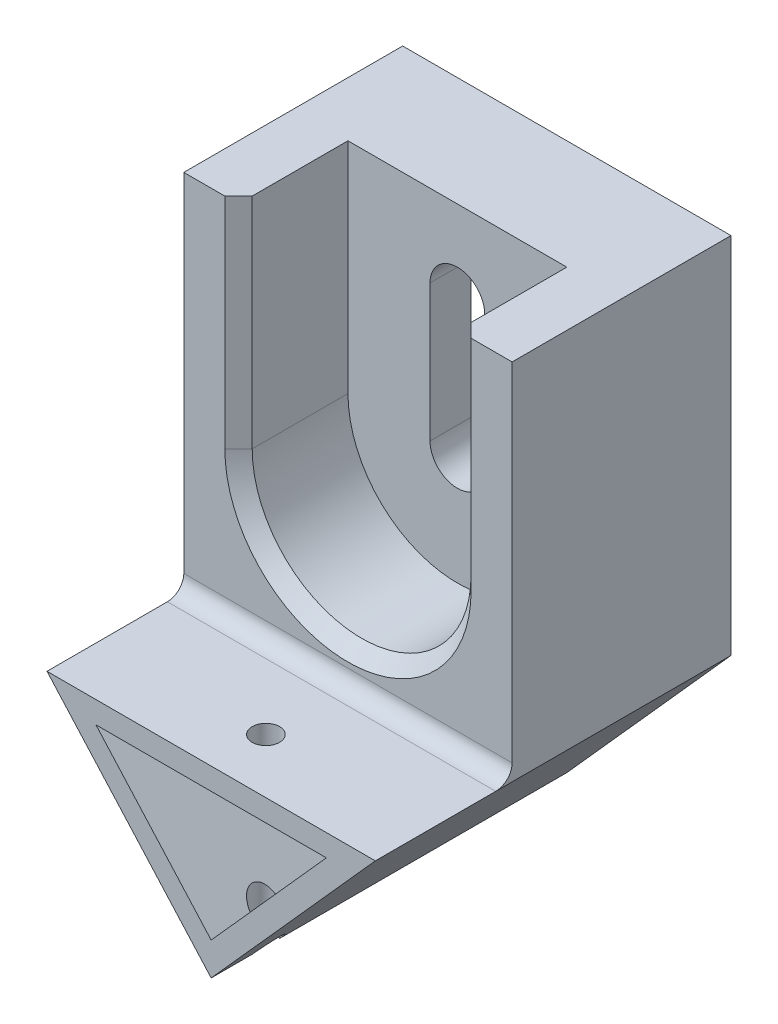
from build123d import *

# Parameters (mm, degrees)
BOSS_EXTRUDE1_DEPTH = 130
SKETCH2_W           = 120
SKETCH2_H           = 132.917960675
BOSS_EXTRUDE2_DEPTH = 80
SKETCH3_R           = 5
CUT_EXTRUDE1_DEPTH  = 68.082039325
CUT_EXTRUDE3_DEPTH  = 40
CHAMFER1_SIZE       = 5
FILLET1_R           = 6
CUT_EXTRUDE4_DEPTH  = 41
SKETCH6_W           = 84.22291236
SKETCH6_H           = 130.917960675
CUT_EXTRUDE5_DEPTH  = 25


with BuildPart() as part:
    # Sketch1 → Boss-Extrude1 (new body)
    with BuildSketch(Plane.XY):
        Polygon((0, 0), (-60, 67.082039325), (60, 67.082039325), align=None)
        Polygon((0, 12), (-42.11145618, 59.082039325), (42.11145618, 59.082039325), align=None, mode=Mode.SUBTRACT)
    extrude(amount=BOSS_EXTRUDE1_DEPTH)

    # Sketch2 → Boss-Extrude2 (add)
    with BuildSketch(Plane(origin=(0, 0, 0), x_dir=(-1, 0, 0), z_dir=(0, 0, -1))):
        with Locations((0, 133.541019662)):
            Rectangle(SKETCH2_W, SKETCH2_H)
    extrude(amount=-BOSS_EXTRUDE2_DEPTH)

    # Sketch3 → Cut-Extrude1 (cut, through all)
    with BuildSketch(Plane(origin=(0, 67.082039325, 0), x_dir=(1, 0, 0), z_dir=(0, 1, 0))):
        with Locations((0, -110)):
            Circle(SKETCH3_R)
    extrude(amount=-CUT_EXTRUDE1_DEPTH, mode=Mode.SUBTRACT)

    # Sketch4 → Cut-Extrude3 (cut)
    with BuildSketch(Plane.XY.offset(80)):
        with BuildLine():
            Line((-40, 200), (-40, 120))
            ThreePointArc((-40, 120), (0, 80), (40, 120))
            Line((40, 120), (40, 200))
            Line((40, 200), (-40, 200))
        make_face()
    extrude(amount=-CUT_EXTRUDE3_DEPTH, mode=Mode.SUBTRACT)

    # Chamfer1
    chamfer1_edges = [part.edges().sort_by_distance(p)[0] for p in [
        (-40, 160, 80),
        (0, 80, 80),
        (40, 160, 80),
    ]]
    chamfer(chamfer1_edges, length=CHAMFER1_SIZE)

    # Fillet1
    fillet1_edges = [part.edges().sort_by_distance(p)[0] for p in [
        (0, 67.082039325, 80),
    ]]
    fillet(fillet1_edges, radius=FILLET1_R)

    # Sketch5 → Cut-Extrude4 (cut, through all)
    with BuildSketch(Plane.XY.offset(40)):
        with BuildLine():
            Line((10, 170), (10, 120))
            ThreePointArc((10, 120), (0, 110), (-10, 120))
            Line((-10, 120), (-10, 170))
            ThreePointArc((-10, 170), (0, 180), (10, 170))
        make_face()
    extrude(amount=-CUT_EXTRUDE4_DEPTH, mode=Mode.SUBTRACT)

    # Sketch6 → Cut-Extrude5 (cut)
    with BuildSketch(Plane(origin=(0, 0, 0), x_dir=(-1, 0, 0), z_dir=(0, 0, -1))):
        with Locations((0, 124.541019663)):
            Rectangle(SKETCH6_W, SKETCH6_H)
    extrude(amount=-CUT_EXTRUDE5_DEPTH, mode=Mode.SUBTRACT)


solid = part.part
